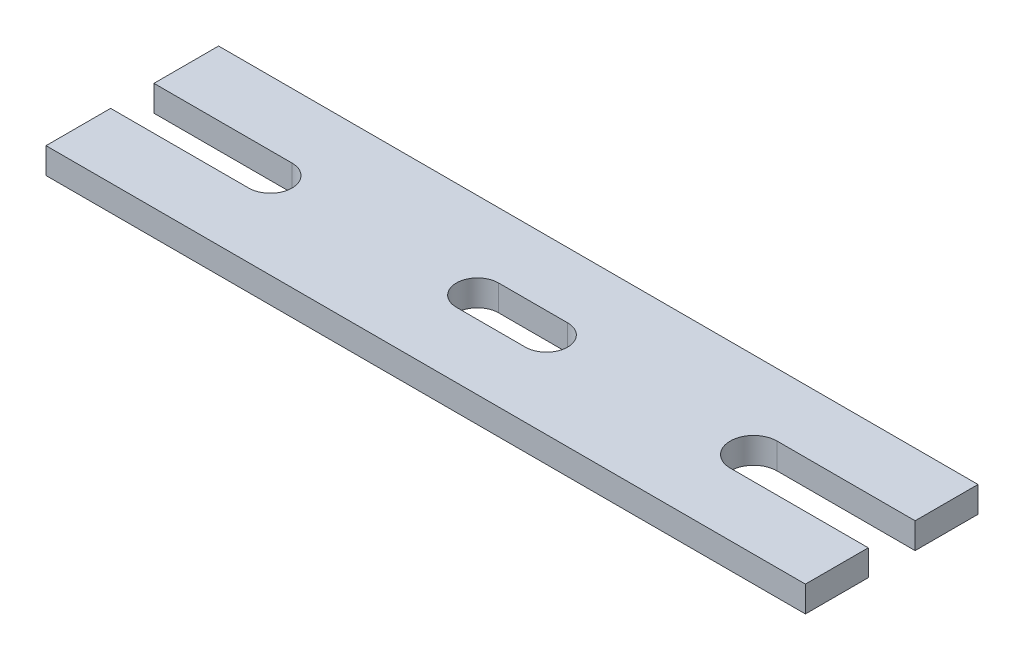
from build123d import *

# Parameters (mm, degrees)
SKETCH1_W           = 279.4
SKETCH1_H           = 63.5
BOSS_EXTRUDE1_DEPTH = 9.525
CUT_EXTRUDE5_DEPTH  = 10.525
CUT_EXTRUDE7_DEPTH  = 10.525
CUT_EXTRUDE8_DEPTH  = 10.525


with BuildPart() as part:
    # Sketch1 → Boss-Extrude1 (new body)
    with BuildSketch(Plane(origin=(0, 0, 0), x_dir=(1, 0, 0), z_dir=(0, 1, 0))):
        Rectangle(SKETCH1_W, SKETCH1_H)
    extrude(amount=BOSS_EXTRUDE1_DEPTH)

    # Sketch9 → Cut-Extrude5 (cut, through all)
    with BuildSketch(Plane(origin=(0, 9.525, 0), x_dir=(1, 0, 0), z_dir=(0, 1, 0))):
        with BuildLine():
            Line((-139.7, 7.969965865), (-88.9, 7.969965865))
            ThreePointArc((-88.9, 7.969965865), (-80.930034135, 0), (-88.9, -7.969965865))
            Line((-88.9, -7.969965865), (-139.7, -7.969965865))
            Line((-139.7, -7.969965865), (-139.7, 7.969965865))
        make_face()
    extrude(amount=-CUT_EXTRUDE5_DEPTH, mode=Mode.SUBTRACT)

    # Sketch12 → Cut-Extrude7 (cut, through all)
    with BuildSketch(Plane(origin=(0, 9.525, 0), x_dir=(1, 0, 0), z_dir=(0, 1, 0))):
        with BuildLine():
            Line((139.7, -8.618596636), (88.9, -8.618596636))
            ThreePointArc((88.9, -8.618596636), (80.281403364, 0), (88.9, 8.618596636))
            Line((88.9, 8.618596636), (139.7, 8.618596636))
            Line((139.7, 8.618596636), (139.7, -8.618596636))
        make_face()
    extrude(amount=-CUT_EXTRUDE7_DEPTH, mode=Mode.SUBTRACT)

    # Sketch13 → Cut-Extrude8 (cut, through all)
    with BuildSketch(Plane(origin=(0, 9.525, 0), x_dir=(1, 0, 0), z_dir=(0, 1, 0))):
        with BuildLine():
            Line((-12.7, 7.761111111), (12.7, 7.761111111))
            ThreePointArc((12.7, 7.761111111), (20.461111111, 0), (12.7, -7.761111111))
            Line((12.7, -7.761111111), (-12.7, -7.761111111))
            ThreePointArc((-12.7, -7.761111111), (-20.461111111, 0), (-12.7, 7.761111111))
        make_face()
    extrude(amount=-CUT_EXTRUDE8_DEPTH, mode=Mode.SUBTRACT)


solid = part.part
